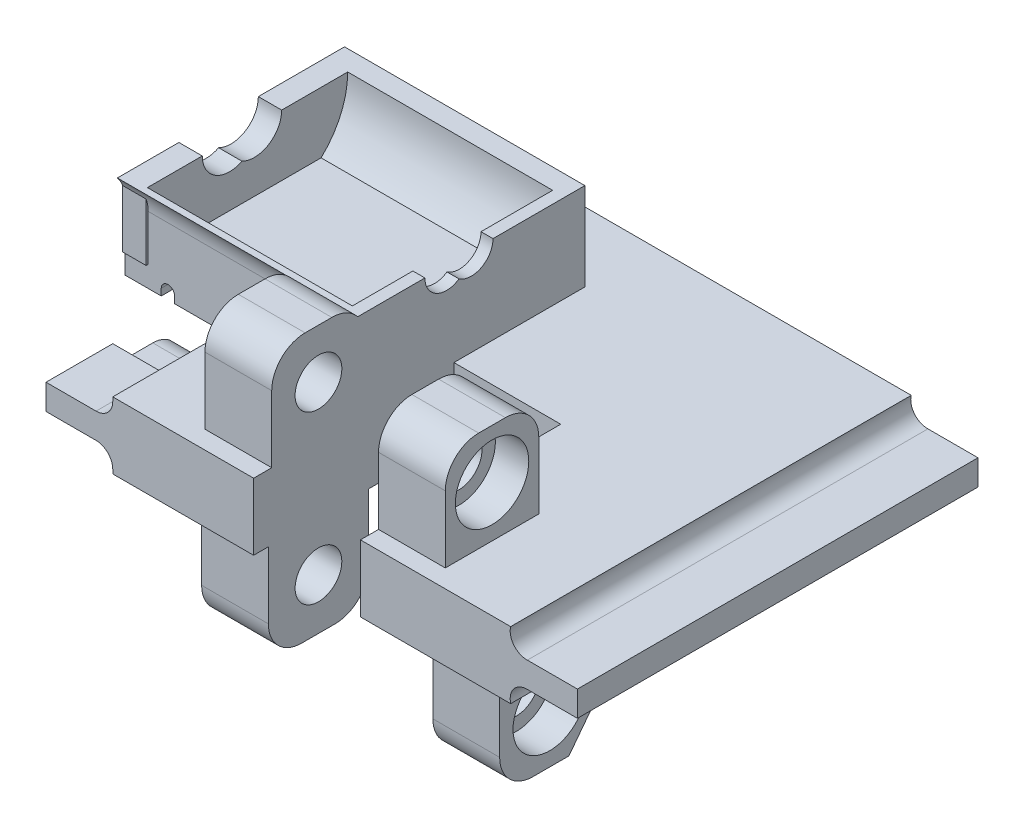
from build123d import *

# Parameters (mm, degrees)
EXTRUDE_1_DEPTH          = 60
CUT_EXTRUDE_1_DEPTH      = 17.3
SKETCH1_W                = 16
SKETCH1_H                = 30
CUT_EXTRUDE1_DEPTH       = 10
SKETCH2_R                = 3.5
BOSS_EXTRUDE1_DEPTH      = 10
SKETCH4_R                = 5.5
CUT_EXTRUDE4_DEPTH       = 5
SKETCH5_R                = 3.5
BOSS_EXTRUDE2_DEPTH      = 10
SKETCH6_R                = 5.5
CUT_EXTRUDE5_DEPTH       = 5
BOSS_EXTRUDE4_DEPTH      = 36
SKETCH8_W                = 1.8
SKETCH8_H                = 30.375385669
SKETCH8_W_2              = 3.5
SKETCH8_H_2              = 30.204879213
BOSS_EXTRUDE5_DEPTH      = 10
CUT_EXTRUDE6_DEPTH       = 10
CUT_EXTRUDE7_DEPTH       = 10
CUT_EXTRUDE8_DEPTH       = 68.060525711
CUT_EXTRUDE9_DEPTH       = 10
CUT_EXTRUDE10_DEPTH      = 2
CUT_EXTRUDE10_DEPTH_BACK = 35


with BuildPart() as part:
    # 스케치1 → 보스-돌출1 (new body)
    with BuildSketch(Plane.XY):
        with BuildLine():
            Line((29.8, 10), (-29.8, 10))
            Line((-29.8, 10), (-29.8, 9.4))
            ThreePointArc((-29.8, 9.4), (-30.532233047, 7.632233047), (-32.3, 6.9))
            Line((-32.3, 6.9), (-39.8, 6.9))
            Line((-39.8, 6.9), (-39.8, 3.1))
            Line((-39.8, 3.1), (-32.3, 3.1))
            ThreePointArc((-32.3, 3.1), (-30.532233047, 2.367766953), (-29.8, 0.6))
            Line((-29.8, 0.6), (-29.8, 0))
            Line((-29.8, 0), (29.8, 0))
            ThreePointArc((29.8, 0), (30.280633401, 2.170456935), (32.3, 3.1))
            Line((32.3, 3.1), (39.8, 3.1))
            Line((39.8, 3.1), (39.8, 6.9))
            Line((39.8, 6.9), (32.3, 6.9))
            ThreePointArc((32.3, 6.9), (30.280633401, 7.829543065), (29.8, 10))
        make_face()
    extrude(amount=EXTRUDE_1_DEPTH)

    # 스케치2 → 컷-돌출1 (cut)
    with BuildSketch(Plane.ZY.offset(39.8)):
        with BuildLine():
            Line((44, 4), (50, 4))
            Line((50, 4), (50, 8))
            Line((50, 8), (10, 8))
            Line((10, 8), (10, 4))
            Line((10, 4), (16, 4))
            ThreePointArc((16, 4), (18.828427125, 2.828427125), (20, 0))
            Line((20, 0), (40, 0))
            ThreePointArc((40, 0), (41.171572875, 2.828427125), (44, 4))
        make_face()
    extrude(amount=-CUT_EXTRUDE_1_DEPTH, mode=Mode.SUBTRACT)

    # Sketch1 → Cut-Extrude1 (cut)
    with BuildSketch(Plane(origin=(0, 10, 0), x_dir=(1, 0, 0), z_dir=(0, 1, 0))):
        with Locations((-0.7, -45)):
            Rectangle(SKETCH1_W, SKETCH1_H)
    extrude(amount=-CUT_EXTRUDE1_DEPTH, mode=Mode.SUBTRACT)

    # Sketch2 → Boss-Extrude1 (add)
    with BuildSketch(Plane.ZY.offset(-7.3)):
        with BuildLine():
            Line((57.29, 10), (43.29, 10))
            Line((43.29, 10), (43.29, 20))
            ThreePointArc((43.29, 20), (44.754466094, 23.535533906), (48.29, 25))
            Line((48.29, 25), (52.29, 25))
            ThreePointArc((52.29, 25), (55.825533906, 23.535533906), (57.29, 20))
            Line((57.29, 20), (57.29, 10))
        make_face()
        with Locations((50.29, 17.61)):
            Circle(SKETCH2_R, mode=Mode.SUBTRACT)
    boss_extrude1 = extrude(amount=-BOSS_EXTRUDE1_DEPTH)

    # Sketch4 → Cut-Extrude4 (cut)
    with BuildSketch(Plane(origin=(17.3, 0, 0), x_dir=(0, 0, -1), z_dir=(1, 0, 0))):
        with Locations((-50.29, 17.61)):
            Circle(SKETCH4_R)
    cut_extrude4 = extrude(amount=-CUT_EXTRUDE4_DEPTH, mode=Mode.SUBTRACT)

    # Mirror1: Boss-Extrude1, Cut-Extrude4 across plane
    add(boss_extrude1.mirror(Plane.ZY.offset(0.7)))
    add(cut_extrude4.mirror(Plane.ZY.offset(0.7)), mode=Mode.SUBTRACT)

    # Sketch5 → Boss-Extrude2 (add)
    with BuildSketch(Plane(origin=(-8.7, 0, 0), x_dir=(0, 0, -1), z_dir=(1, 0, 0))):
        with BuildLine():
            Line((-57.79, 0), (-42.79, 0))
            Line((-42.79, 0), (-42.79, -10))
            ThreePointArc((-42.79, -10), (-44.254466094, -13.535533906), (-47.79, -15))
            Line((-47.79, -15), (-52.79, -15))
            ThreePointArc((-52.79, -15), (-56.325533906, -13.535533906), (-57.79, -10))
            Line((-57.79, -10), (-57.79, 0))
        make_face()
        with Locations((-50.29, -7.39000045)):
            Circle(SKETCH5_R, mode=Mode.SUBTRACT)
    boss_extrude2 = extrude(amount=-BOSS_EXTRUDE2_DEPTH)

    # Sketch6 → Cut-Extrude5 (cut)
    with BuildSketch(Plane.ZY.offset(18.7)):
        with Locations((50.29, -7.39000045)):
            Circle(SKETCH6_R)
    cut_extrude5 = extrude(amount=-CUT_EXTRUDE5_DEPTH, mode=Mode.SUBTRACT)

    # Mirror2: Boss-Extrude2, Cut-Extrude5 across plane
    add(boss_extrude2.mirror(Plane(origin=(3.62, 0, 0), x_dir=(0, 0, 1), z_dir=(1, 0, 0))))
    add(cut_extrude5.mirror(Plane(origin=(3.62, 0, 0), x_dir=(0, 0, 1), z_dir=(1, 0, 0))), mode=Mode.SUBTRACT)

    # Sketch7 → Boss-Extrude4 (add)
    with BuildSketch(Plane(origin=(-8.7, 0, 0), x_dir=(0, 0, -1), z_dir=(1, 0, 0))):
        with BuildLine():
            Line((-17.393692115, 14), (-39.426307885, 14))
            ThreePointArc((-39.426307885, 14), (-42.370886715, 18.160202838), (-43.41, 23.15))
            Line((-43.41, 23.15), (-44.407024337, 23.15))
            ThreePointArc((-44.407024337, 23.15), (-43.577523034, 21.671095701), (-43.29, 20))
            Line((-43.29, 20), (-43.29, 10))
            Line((-43.29, 10), (-30, 10))
            Line((-30, 10), (-10.385441698, 10))
            Line((-10.385441698, 10), (-10.385441698, 23.15))
            Line((-10.385441698, 23.15), (-13.41, 23.15))
            ThreePointArc((-13.41, 23.15), (-14.449113285, 18.160202838), (-17.393692115, 14))
        make_face()
    extrude(amount=-BOSS_EXTRUDE4_DEPTH)

    # Sketch8 → Boss-Extrude5 (add)
    with BuildSketch(Plane(origin=(0, 23.15, 0), x_dir=(1, 0, 0), z_dir=(0, 1, 0))):
        with Locations((-9.6, -28.597692835)):
            Rectangle(SKETCH8_W, SKETCH8_H)
        with Locations((-42.95, -28.512439607)):
            Rectangle(SKETCH8_W_2, SKETCH8_H_2)
    extrude(amount=-BOSS_EXTRUDE5_DEPTH)

    # Sketch9 → Cut-Extrude6 (cut)
    with BuildSketch(Plane(origin=(-8.7, 0, 0), x_dir=(0, 0, -1), z_dir=(1, 0, 0))):
        with BuildLine():
            Line((-27.846233017, 23.15), (-24.146233017, 23.15))
            ThreePointArc((-24.146233017, 23.15), (-25.887922704, 26.028801834), (-29.246233017, 25.822077843))
            ThreePointArc((-29.246233017, 25.822077843), (-28.217431183, 24.658310313), (-27.846233017, 23.15))
        make_face()
        with BuildLine():
            ThreePointArc((-29.246233017, 20.477922157), (-25.887922704, 20.271198166), (-24.146233017, 23.15))
            Line((-24.146233017, 23.15), (-27.846233017, 23.15))
            ThreePointArc((-27.846233017, 23.15), (-28.217431183, 21.641689687), (-29.246233017, 20.477922157))
        make_face()
        with BuildLine():
            ThreePointArc((-27.846233017, 23.15), (-28.217431183, 24.658310313), (-29.246233017, 25.822077843))
            ThreePointArc((-29.246233017, 25.822077843), (-30.275034851, 24.658310313), (-30.646233017, 23.15))
            Line((-30.646233017, 23.15), (-27.846233017, 23.15))
        make_face()
        with BuildLine():
            ThreePointArc((-30.646233017, 23.15), (-30.275034851, 24.658310313), (-29.246233017, 25.822077843))
            ThreePointArc((-29.246233017, 25.822077843), (-32.60454333, 26.028801834), (-34.346233017, 23.15))
            Line((-34.346233017, 23.15), (-30.646233017, 23.15))
        make_face()
        with BuildLine():
            ThreePointArc((-34.346233017, 23.15), (-32.60454333, 20.271198166), (-29.246233017, 20.477922157))
            ThreePointArc((-29.246233017, 20.477922157), (-30.275034851, 21.641689687), (-30.646233017, 23.15))
            Line((-30.646233017, 23.15), (-34.346233017, 23.15))
        make_face()
        with BuildLine():
            ThreePointArc((-30.646233017, 23.15), (-30.275034851, 21.641689687), (-29.246233017, 20.477922157))
            ThreePointArc((-29.246233017, 20.477922157), (-28.217431183, 21.641689687), (-27.846233017, 23.15))
            Line((-27.846233017, 23.15), (-30.646233017, 23.15))
        make_face()
    extrude(amount=-CUT_EXTRUDE6_DEPTH, mode=Mode.SUBTRACT)

    # Sketch10 → Cut-Extrude7 (cut)
    with BuildSketch(Plane.ZY.offset(44.7)):
        with BuildLine():
            Line((26.996233017, 23.15), (31.496233017, 23.15))
            ThreePointArc((31.496233017, 23.15), (30.888724964, 25.297673159), (29.246233017, 26.808893275))
            ThreePointArc((29.246233017, 26.808893275), (27.60374107, 25.297673159), (26.996233017, 23.15))
        make_face()
        with BuildLine():
            Line((35.196233017, 23.15), (31.496233017, 23.15))
            ThreePointArc((31.496233017, 23.15), (30.888724964, 21.002326841), (29.246233017, 19.491106725))
            ThreePointArc((29.246233017, 19.491106725), (33.243906177, 19.657508053), (35.196233017, 23.15))
        make_face()
        with BuildLine():
            ThreePointArc((29.246233017, 26.808893275), (30.888724964, 25.297673159), (31.496233017, 23.15))
            Line((31.496233017, 23.15), (35.196233017, 23.15))
            ThreePointArc((35.196233017, 23.15), (33.243906177, 26.642491947), (29.246233017, 26.808893275))
        make_face()
        with BuildLine():
            ThreePointArc((29.246233017, 19.491106725), (30.888724964, 21.002326841), (31.496233017, 23.15))
            Line((31.496233017, 23.15), (26.996233017, 23.15))
            ThreePointArc((26.996233017, 23.15), (27.60374107, 21.002326841), (29.246233017, 19.491106725))
        make_face()
        with BuildLine():
            ThreePointArc((26.996233017, 23.15), (27.60374107, 25.297673159), (29.246233017, 26.808893275))
            ThreePointArc((29.246233017, 26.808893275), (25.248559858, 26.642491947), (23.296233017, 23.15))
            Line((23.296233017, 23.15), (26.996233017, 23.15))
        make_face()
        with BuildLine():
            ThreePointArc((23.296233017, 23.15), (25.248559858, 19.657508053), (29.246233017, 19.491106725))
            ThreePointArc((29.246233017, 19.491106725), (27.60374107, 21.002326841), (26.996233017, 23.15))
            Line((26.996233017, 23.15), (23.296233017, 23.15))
        make_face()
    extrude(amount=-CUT_EXTRUDE7_DEPTH, mode=Mode.SUBTRACT)

    # Sketch11 → Cut-Extrude8 (cut, through all)
    with BuildSketch(Plane.XY.offset(43.29)):
        with BuildLine():
            Line((-39.25, 10), (-39.25, 11))
            ThreePointArc((-39.25, 11), (-38.25, 12), (-37.25, 11))
            Line((-37.25, 11), (-37.25, 10))
            Line((-37.25, 10), (-39.25, 10))
        make_face()
    extrude(amount=-CUT_EXTRUDE8_DEPTH, mode=Mode.SUBTRACT)

    # Sketch12 → Cut-Extrude9 (cut)
    with BuildSketch(Plane(origin=(25.94, 0, 0), x_dir=(0, 0, -1), z_dir=(1, 0, 0))):
        Polygon((-42.79, -8.93619037), (-47.402449947, -14.984957869), (-43.167493301, -15.543555396), (-40.889176965, -10), align=None)
    extrude(amount=-CUT_EXTRUDE9_DEPTH, mode=Mode.SUBTRACT)

    # Sketch13 → Cut-Extrude10 (cut, two sides)
    with BuildSketch(Plane.XY.offset(43.29)) as cut_extrude10_sk:
        with BuildLine():
            Line((-29.8, 10), (-23.780440028, 10))
            Line((-23.780440028, 10), (-23.780440028, 11.102878987))
            ThreePointArc((-23.780440028, 11.102878987), (-22.780440028, 12.102878987), (-21.780440028, 11.102878987))
            Line((-21.780440028, 11.102878987), (-21.780440028, 9))
            Line((-21.780440028, 9), (-30.475963693, 9))
            Line((-30.475963693, 9), (-29.8, 10))
        make_face()
    extrude(amount=CUT_EXTRUDE10_DEPTH, mode=Mode.SUBTRACT)
    extrude(cut_extrude10_sk.sketch, amount=-CUT_EXTRUDE10_DEPTH_BACK, mode=Mode.SUBTRACT)


solid = part.part
